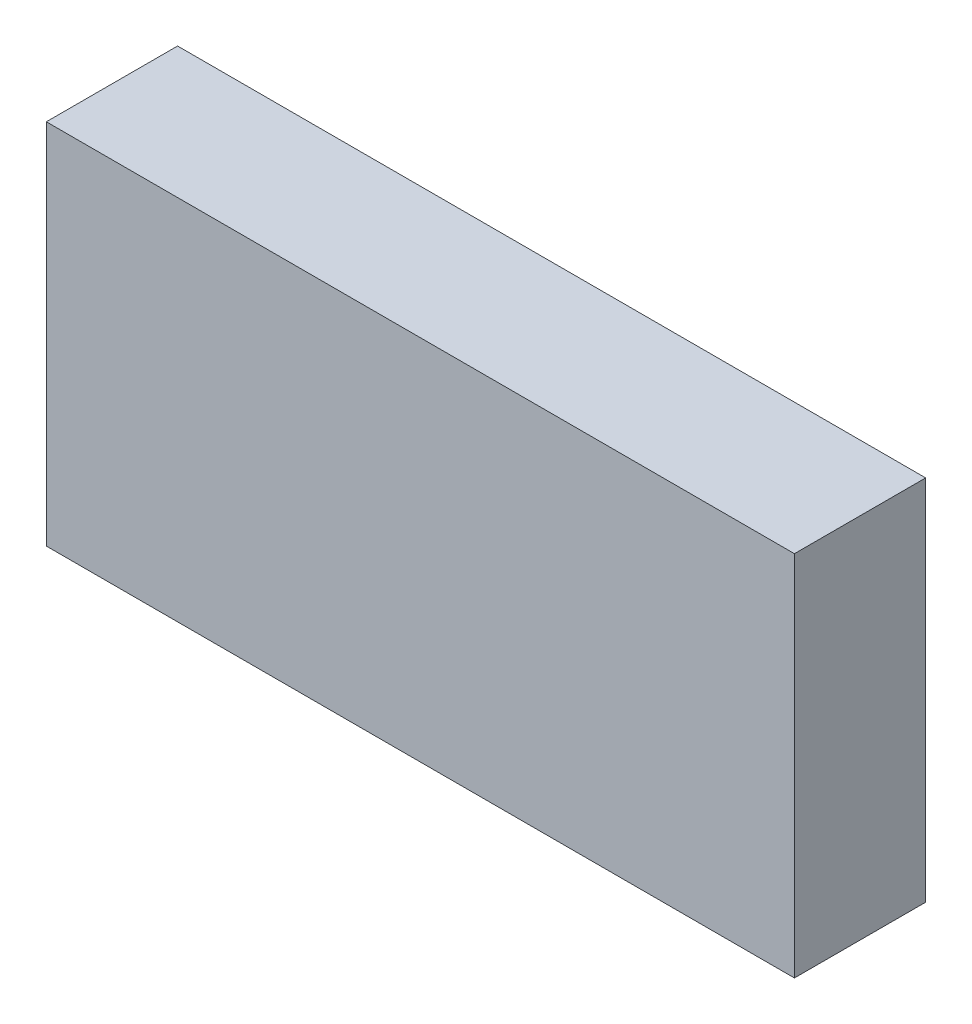
from build123d import *

# Parameters (mm, degrees)
SKETCH_1_W      = 57
SKETCH_1_H      = 28
EXTRUDE_1_DEPTH = 10


with BuildPart() as part:
    # 草图1 → 凸台-拉伸1 (new body)
    with BuildSketch(Plane.XY):
        Rectangle(SKETCH_1_W, SKETCH_1_H)
    extrude(amount=EXTRUDE_1_DEPTH)


solid = part.part
